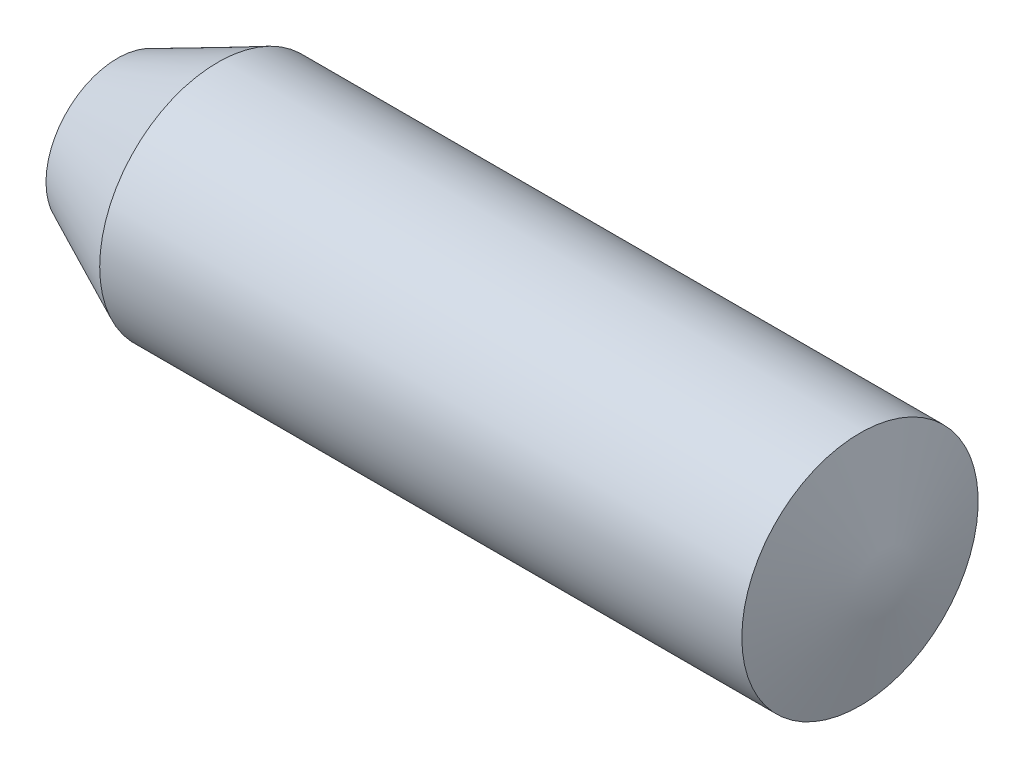
from build123d import *


with BuildPart() as part:
    # Sketch1 → Revolve1 (revolve)
    with BuildSketch(Plane.XY):
        Polygon((0, 0), (0, 169.096871333), (237.245718475, 279.4), (1755.508482821, 279.4), (1828.8, 0), align=None)
    revolve(axis=Axis((0, 0, 0), (1, 0, 0)))


solid = part.part
